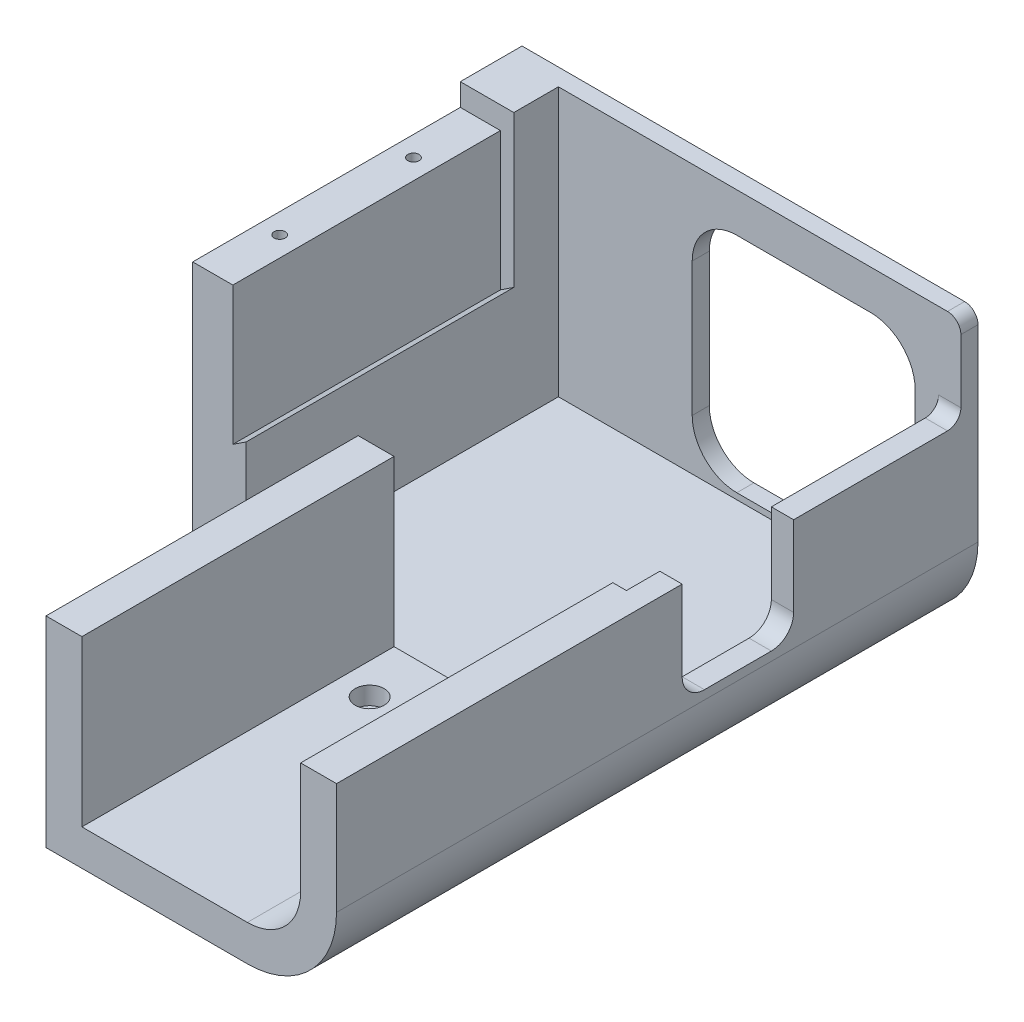
from build123d import *

# Parameters (mm, degrees)
BOSS_EXTRUDE1_DEPTH            = 70
BOSS_EXTRUDE2_DEPTH            = 70
CUT_EXTRUDE1_DEPTH             = 60
SKETCH13_W                     = 9
SKETCH13_H                     = 60
CUT_EXTRUDE3_DEPTH             = 5
SKETCH12_W                     = 25
SKETCH12_H                     = 23
CUT_EXTRUDE2_DEPTH             = 5
BOSS_EXTRUDE3_DEPTH            = 3.84
CBORE_FOR_M3_SHCS1_D           = 3.4
CBORE_FOR_M3_SHCS1_DEPTH       = 8.05
CBORE_FOR_M3_SHCS1_CBORE_D     = 6.5
CBORE_FOR_M3_SHCS1_CBORE_DEPTH = 4
CBORE_FOR_M3_SHCS1_TIP         = 1.021463052
M3X0_5_TAPPED_HOLE1_D          = 2.5
M3X0_5_TAPPED_HOLE1_DEPTH      = 14
M3X0_5_TAPPED_HOLE1_TIP        = 0.751075774
FILLET1_R                      = 10
FILLET4_R                      = 5
FILLET5_R                      = 3


with BuildPart() as part:
    # Sketch3 → Boss-Extrude1 (new body)
    with BuildSketch(Plane.XY):
        with BuildLine():
            Line((85.25, 15), (85.25, 40))
            Line((85.25, 40), (90.25, 40))
            Line((90.25, 40), (90.25, 15))
            ThreePointArc((90.25, 15), (84.392135624, 0.857864376), (70.25, -5))
            Line((70.25, -5), (-12, -5))
            Line((-12, -5), (-12, 60.2))
            Line((-12, 60.2), (0, 60.2))
            Line((0, 60.2), (0, 0))
            Line((0, 0), (70.25, 0))
            ThreePointArc((70.25, 0), (80.856601718, 4.393398282), (85.25, 15))
        make_face()
    extrude(amount=BOSS_EXTRUDE1_DEPTH)

    # Sketch5 → Boss-Extrude2 (add)
    with BuildSketch(Plane.XY.offset(70)):
        with BuildLine():
            Line((82.2, 15), (82.2, 40))
            Line((82.2, 40), (90.25, 40))
            Line((90.25, 40), (90.25, 15))
            ThreePointArc((90.25, 15), (84.392135624, 0.857864376), (70.25, -5))
            Line((70.25, -5), (25.1, -5))
            Line((25.1, -5), (25.1, 40))
            Line((25.1, 40), (33.15, 40))
            Line((33.15, 40), (33.15, 3.05))
            Line((33.15, 3.05), (70.25, 3.05))
            ThreePointArc((70.25, 3.05), (78.699926035, 6.550073965), (82.2, 15))
        make_face()
    extrude(amount=BOSS_EXTRUDE2_DEPTH)

    # Sketch6 → Cut-Extrude1 (cut)
    with BuildSketch(Plane.XY.offset(70)):
        Polygon((-3, 24.26), (0, 26.24), (0, 60.2), (-3, 60.2), align=None)
    extrude(amount=-CUT_EXTRUDE1_DEPTH, mode=Mode.SUBTRACT)

    # Sketch13 → Cut-Extrude3 (cut)
    with BuildSketch(Plane(origin=(0, 60.2, 0), x_dir=(1, 0, 0), z_dir=(0, 1, 0))):
        with Locations((-7.5, -40)):
            Rectangle(SKETCH13_W, SKETCH13_H)
    extrude(amount=-CUT_EXTRUDE3_DEPTH, mode=Mode.SUBTRACT)

    # Sketch12 → Cut-Extrude2 (cut)
    with BuildSketch(Plane(origin=(90.25, 0, 0), x_dir=(0, 0, -1), z_dir=(1, 0, 0))):
        with Locations((-50, 28.5)):
            Rectangle(SKETCH12_W, SKETCH12_H)
    extrude(amount=-CUT_EXTRUDE2_DEPTH, mode=Mode.SUBTRACT)

    # Sketch7 → Boss-Extrude3 (add)
    with BuildSketch(Plane.XY):
        with BuildLine():
            Line((-12, 60.2), (-12, -5))
            Line((-12, -5), (70.25, -5))
            ThreePointArc((70.25, -5), (84.392135624, 0.857864376), (90.25, 15))
            Line((90.25, 15), (90.25, 60.2))
            Line((90.25, 60.2), (-12, 60.2))
        make_face()
        with BuildLine():
            Line((70, 51.37), (40, 51.37))
            ThreePointArc((40, 51.37), (32.928932188, 48.441067812), (30, 41.37))
            Line((30, 41.37), (30, 11.37))
            ThreePointArc((30, 11.37), (32.928932188, 4.298932188), (40, 1.37))
            Line((40, 1.37), (70, 1.37))
            ThreePointArc((70, 1.37), (77.071067812, 4.298932188), (80, 11.37))
            Line((80, 11.37), (80, 41.37))
            ThreePointArc((80, 41.37), (77.071067812, 48.441067812), (70, 51.37))
        make_face(mode=Mode.SUBTRACT)
    extrude(amount=-BOSS_EXTRUDE3_DEPTH)

    # CBORE for M3 SHCS1
    with Locations(Plane(origin=(0, 3.05, 0), x_dir=(1, 0, 0), z_dir=(0, 1, 0))):
        with Locations((40.175, -82.5), (55.175, -82.5)):
            CounterBoreHole(CBORE_FOR_M3_SHCS1_D / 2, CBORE_FOR_M3_SHCS1_CBORE_D / 2, CBORE_FOR_M3_SHCS1_CBORE_DEPTH, depth=CBORE_FOR_M3_SHCS1_DEPTH)
            with Locations((0, 0, -(CBORE_FOR_M3_SHCS1_DEPTH + CBORE_FOR_M3_SHCS1_TIP / 2))):  # 118° drill point
                Cone(0, CBORE_FOR_M3_SHCS1_D / 2, CBORE_FOR_M3_SHCS1_TIP, mode=Mode.SUBTRACT)

    # M3x0.5 Tapped Hole1
    with Locations(Plane(origin=(0, 55.2, 0), x_dir=(1, 0, 0), z_dir=(0, 1, 0))):
        with Locations((-7.5, -25), (-7.5, -55)):
            Hole(M3X0_5_TAPPED_HOLE1_D / 2, depth=M3X0_5_TAPPED_HOLE1_DEPTH)
            with Locations((0, 0, -(M3X0_5_TAPPED_HOLE1_DEPTH + M3X0_5_TAPPED_HOLE1_TIP / 2))):  # 118° drill point
                Cone(0, M3X0_5_TAPPED_HOLE1_D / 2, M3X0_5_TAPPED_HOLE1_TIP, mode=Mode.SUBTRACT)

    # Fillet1
    fillet1_edges = [part.edges().sort_by_distance(p)[0] for p in [
        (25.1, -2.5, 70),
    ]]
    fillet(fillet1_edges, radius=FILLET1_R)

    # Fillet4
    fillet4_edges = [part.edges().sort_by_distance(p)[0] for p in [
        (87.75, 17, 37.5),
        (87.75, 17, 62.5),
    ]]
    fillet(fillet4_edges, radius=FILLET4_R)

    # Fillet5
    fillet5_edges = [part.edges().sort_by_distance(p)[0] for p in [
        (87.75, 40, 0),
        (90.25, 60.2, -1.92),
    ]]
    fillet(fillet5_edges, radius=FILLET5_R)


solid = part.part
